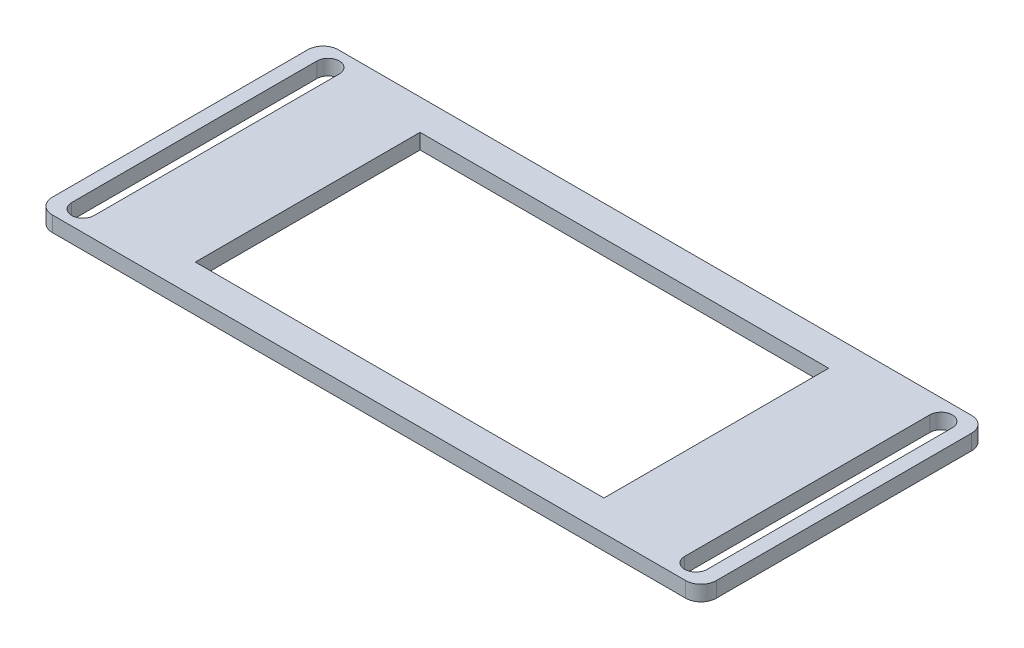
from build123d import *

# Parameters (mm, degrees)
SKETCH1_W           = 65
SKETCH1_H           = 28
SKETCH1_W_2         = 40
SKETCH1_H_2         = 22
BOSS_EXTRUDE1_DEPTH = 1.5
CUT_EXTRUDE1_DEPTH  = 2.5
FILLET2_R           = 1.5


with BuildPart() as part:
    # Sketch1 → Boss-Extrude1 (new body)
    with BuildSketch(Plane(origin=(0, 0, 0), x_dir=(1, 0, 0), z_dir=(0, 1, 0))):
        Rectangle(SKETCH1_W, SKETCH1_H)
        Rectangle(SKETCH1_W_2, SKETCH1_H_2, mode=Mode.SUBTRACT)
    extrude(amount=BOSS_EXTRUDE1_DEPTH)

    # Sketch2 → Cut-Extrude1 (cut, through all)
    with BuildSketch(Plane(origin=(0, 1.5, 0), x_dir=(1, 0, 0), z_dir=(0, 1, 0))):
        with BuildLine():
            Line((-31.1, -12), (-31.1, 12))
            ThreePointArc((-31.1, 12), (-30, 13.1), (-28.9, 12))
            Line((-28.9, 12), (-28.9, -12))
            ThreePointArc((-28.9, -12), (-30, -13.1), (-31.1, -12))
        make_face()
        with BuildLine():
            Line((31.1, -12), (31.1, 12))
            ThreePointArc((31.1, 12), (30, 13.1), (28.9, 12))
            Line((28.9, 12), (28.9, -12))
            ThreePointArc((28.9, -12), (30, -13.1), (31.1, -12))
        make_face()
    extrude(amount=-CUT_EXTRUDE1_DEPTH, mode=Mode.SUBTRACT)

    # Fillet2
    fillet2_edges = [part.edges().sort_by_distance(p)[0] for p in [
        (32.5, 0.75, 14),
        (-32.5, 0.75, 14),
        (-32.5, 0.75, -14),
        (32.5, 0.75, -14),
    ]]
    fillet(fillet2_edges, radius=FILLET2_R)


solid = part.part
